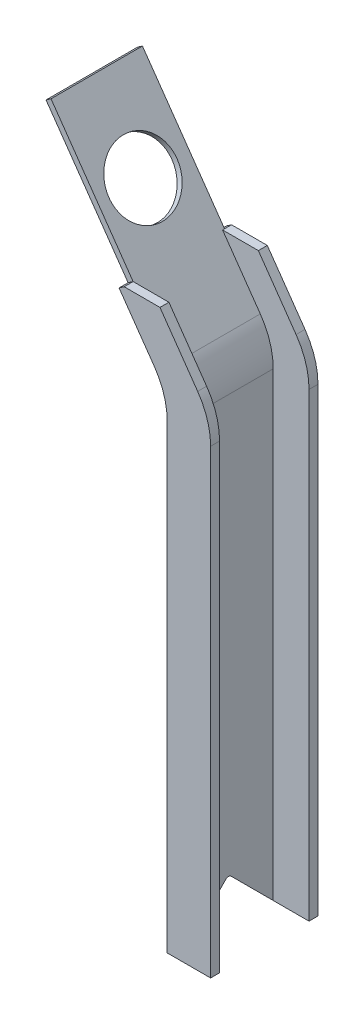
from build123d import *

# Parameters (mm, degrees)
BOSS_EXTRUDE1_DEPTH     = 76.2
BOSS_EXTRUDE8_DEPTH     = 6.35
LPATTERN3_COUNT         = 2
LPATTERN3_PITCH         = 69.85
FILLET2_R               = 50.8
SKETCH12_W              = 64.895089707
SKETCH12_H              = 101.6
BOSS_EXTRUDE10_DEPTH    = 4.318
TOP_CIRCLE_CUT_REACH    = 278.774
SKETCH10_R              = 24.13
CUT_EXTRUDE2_DEPTH      = 26.4
CUT_EXTRUDE2_DEPTH_BACK = 98.777385928
FILLET3_R               = 2.54


with BuildPart() as part:
    # Sketch1 → Boss-Extrude1 (new body)
    with BuildSketch(Plane.XY):
        Polygon((0, 0), (0, 342.9), (-34.18639432, 391.723230906), (-30.558898383, 394.263230906), (-23.731659882, 384.51292385), (5.406023084, 342.9), (5.406023084, 0), align=None)
    extrude(amount=BOSS_EXTRUDE1_DEPTH)

    # Sketch9 → Boss-Extrude8 (add)
    with BuildSketch(Plane.XY):
        Polygon((5.406023084, 0), (30.806023084, 0), (30.806023084, 342.9), (-5.158898383, 394.263230906), (-30.558898383, 394.263230906), (5.406023084, 342.9), align=None)
    boss_extrude8 = extrude(amount=BOSS_EXTRUDE8_DEPTH)

    # LPattern3: Boss-Extrude8 ×2
    with Locations(*[(0, 0, i * LPATTERN3_PITCH) for i in range(1, LPATTERN3_COUNT)]):
        add(boss_extrude8)

    # Fillet2
    fillet2_edges = [part.edges().sort_by_distance(p)[0] for p in [
        (0, 342.9, 38.1),
        (30.806023084, 342.9, 3.175),
        (5.406023084, 342.9, 38.1),
        (30.806023084, 342.9, 73.025),
    ]]
    fillet(fillet2_edges, radius=FILLET2_R)

    # Sketch12 → Boss-Extrude10 (add)
    with BuildSketch(Plane(origin=(164.737795771, 115.350646427, 0), x_dir=(0, 0, -1), z_dir=(0.819152044, 0.573576436, 0))):
        with Locations((-37.402455147, 391.289395618)):
            Rectangle(SKETCH12_W, SKETCH12_H)
    extrude(amount=-BOSS_EXTRUDE10_DEPTH)

    # Sketch10 → Top Circle Cut (cut, up to next)
    with BuildSketch(Plane(origin=(164.737795771, 115.350646427, 0), x_dir=(0, 0, -1), z_dir=(0.819152044, 0.573576436, 0)), mode=Mode.PRIVATE) as top_circle_cut_sk1:
        with Locations((-38.1, 383.669395618)):
            Circle(SKETCH10_R)
    top_circle_cut_tool1 = extrude(top_circle_cut_sk1.sketch, amount=-TOP_CIRCLE_CUT_REACH, mode=Mode.PRIVATE) & part.part
    add(top_circle_cut_tool1.solids().sort_by_distance((-55.325929, 429.634216, 38.1))[0], mode=Mode.SUBTRACT)

    # Sketch13 → Cut-Extrude2 (cut, two sides)
    with BuildSketch(Plane(origin=(5.406023084, 0, 0), x_dir=(0, 0, -1), z_dir=(1, 0, 0))) as cut_extrude2_sk:
        Polygon((-38.1, 31.75), (-69.85, 0), (-6.35, 0), align=None)
    extrude(amount=CUT_EXTRUDE2_DEPTH, mode=Mode.SUBTRACT)
    extrude(cut_extrude2_sk.sketch, amount=-CUT_EXTRUDE2_DEPTH_BACK, mode=Mode.SUBTRACT)

    # Fillet3
    fillet3_edges = [part.edges().sort_by_distance(p)[0] for p in [
        (2.703011542, 31.75, 38.1),
    ]]
    fillet(fillet3_edges, radius=FILLET3_R)


solid = part.part
